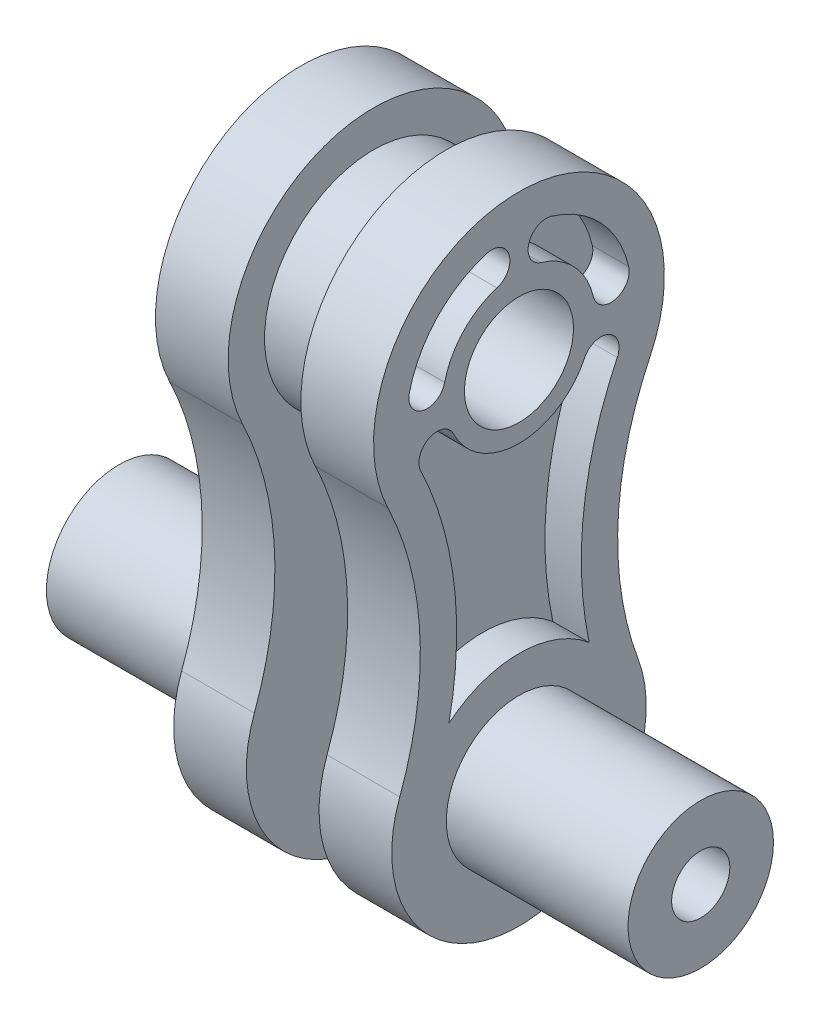
from build123d import *

# Parameters (mm, degrees)
SKETCH1_R           = 30
BOSS_EXTRUDE1_DEPTH = 10
BOSS_EXTRUDE2_DEPTH = 20
SKETCH3_R           = 20
BOSS_EXTRUDE3_DEPTH = 50
CUT_EXTRUDE1_DEPTH  = 10
SKETCH5_R           = 15
CUT_EXTRUDE2_DEPTH  = 41
SKETCH6_R           = 8
CUT_EXTRUDE3_DEPTH  = 91


with BuildPart() as part:
    # Sketch1 → Boss-Extrude1 (new body, symmetric)
    with BuildSketch(Plane(origin=(0, 0, 0), x_dir=(0, 0, -1), z_dir=(1, 0, 0))):
        Circle(SKETCH1_R)
    extrude(amount=BOSS_EXTRUDE1_DEPTH, both=True)

    # Sketch2 → Boss-Extrude2 (add)
    with BuildSketch(Plane(origin=(10, 0, 0), x_dir=(0, 0, -1), z_dir=(1, 0, 0))):
        with BuildLine():
            ThreePointArc((36.043181696, -17.346153846), (0, 40), (-36.043181696, -17.346153846))
            ThreePointArc((-36.043181696, -17.346153846), (-27.235626529, -52.234661385), (-32.799295343, -87.785))
            ThreePointArc((-32.799295343, -87.785), (0, -135), (32.799295343, -87.785))
            ThreePointArc((32.799295343, -87.785), (27.235626529, -52.234661385), (36.043181696, -17.346153846))
        make_face()
    boss_extrude2 = extrude(amount=BOSS_EXTRUDE2_DEPTH)

    # Sketch3 → Boss-Extrude3 (add)
    with BuildSketch(Plane(origin=(30, 0, 0), x_dir=(0, 0, -1), z_dir=(1, 0, 0))):
        with Locations((0, -100)):
            Circle(SKETCH3_R)
    boss_extrude3 = extrude(amount=BOSS_EXTRUDE3_DEPTH)

    # Sketch4 → Cut-Extrude1 (cut)
    with BuildSketch(Plane(origin=(30, 0, 0), x_dir=(0, 0, -1), z_dir=(1, 0, 0))):
        with BuildLine():
            ThreePointArc((30.176724251, 7.096852363), (22.585383623, 21.234416559), (8.942307692, 29.682235986))
            ThreePointArc((8.942307692, 29.682235986), (2.712542583, 26.337086261), (6.057692308, 20.107321152))
            ThreePointArc((6.057692308, 20.107321152), (15.299776003, 14.384604766), (20.442297073, 4.807545149))
            ThreePointArc((20.442297073, 4.807545149), (26.454164269, 1.084985167), (30.176724251, 7.096852363))
        make_face()
        with BuildLine():
            ThreePointArc((-30.176724251, 7.096852363), (-22.585383623, 21.234416559), (-8.942307692, 29.682235986))
            ThreePointArc((-8.942307692, 29.682235986), (-2.712542583, 26.337086261), (-6.057692308, 20.107321152))
            ThreePointArc((-6.057692308, 20.107321152), (-15.299776003, 14.384604766), (-20.442297073, 4.807545149))
            ThreePointArc((-20.442297073, 4.807545149), (-26.454164269, 1.084985167), (-30.176724251, 7.096852363))
        make_face()
        with BuildLine():
            ThreePointArc((27.032386272, -13.009615385), (17.862474513, -44.37894553), (19.296651575, -77.029600831))
            ThreePointArc((19.296651575, -77.029600831), (0, -70), (-19.296651575, -77.029600831))
            ThreePointArc((-19.296651575, -77.029600831), (-17.862474513, -44.37894553), (-27.032386272, -13.009615385))
            ThreePointArc((-27.032386272, -13.009615385), (-24.695257791, -6.335948442), (-18.021590848, -8.673076923))
            ThreePointArc((-18.021590848, -8.673076923), (0, -20), (18.021590848, -8.673076923))
            ThreePointArc((18.021590848, -8.673076923), (24.695257791, -6.335948442), (27.032386272, -13.009615385))
        make_face()
    cut_extrude1 = extrude(amount=-CUT_EXTRUDE1_DEPTH, mode=Mode.SUBTRACT)

    # Sketch5 → Cut-Extrude2 (cut, through all)
    with BuildSketch(Plane(origin=(30, 0, 0), x_dir=(0, 0, -1), z_dir=(1, 0, 0))):
        Circle(SKETCH5_R)
    cut_extrude2 = extrude(amount=-CUT_EXTRUDE2_DEPTH, mode=Mode.SUBTRACT)

    # Sketch6 → Cut-Extrude3 (cut, through all)
    with BuildSketch(Plane(origin=(80, 0, 0), x_dir=(0, 0, -1), z_dir=(1, 0, 0))):
        with Locations((0, -100)):
            Circle(SKETCH6_R)
    cut_extrude3 = extrude(amount=-CUT_EXTRUDE3_DEPTH, mode=Mode.SUBTRACT)

    # Mirror1: Boss-Extrude2, Boss-Extrude3, Cut-Extrude1, Cut-Extrude2, Cut-Extrude3 across plane
    add(boss_extrude2.mirror(Plane(origin=(0, 0, 0), x_dir=(0, 0, 1), z_dir=(1, 0, 0))))
    add(boss_extrude3.mirror(Plane(origin=(0, 0, 0), x_dir=(0, 0, 1), z_dir=(1, 0, 0))))
    add(cut_extrude1.mirror(Plane(origin=(0, 0, 0), x_dir=(0, 0, 1), z_dir=(1, 0, 0))), mode=Mode.SUBTRACT)
    add(cut_extrude2.mirror(Plane(origin=(0, 0, 0), x_dir=(0, 0, 1), z_dir=(1, 0, 0))), mode=Mode.SUBTRACT)
    add(cut_extrude3.mirror(Plane(origin=(0, 0, 0), x_dir=(0, 0, 1), z_dir=(1, 0, 0))), mode=Mode.SUBTRACT)


solid = part.part
